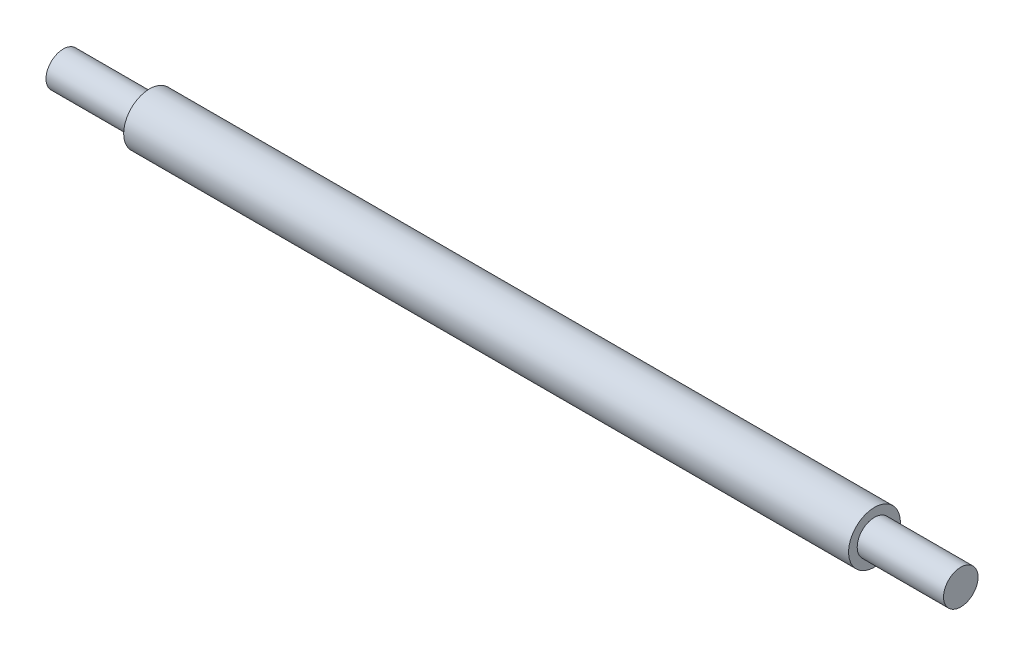
from build123d import *


with BuildPart() as part:
    # Sketch1 → Revolve1 (revolve)
    with BuildSketch(Plane.XY):
        Polygon((-52, 0), (52, 0), (52, 2), (42, 2), (42, 3), (-42, 3), (-42, 2), (-52, 2), align=None)
    revolve(axis=Axis((-52, 0, 0), (1, 0, 0)))


solid = part.part
